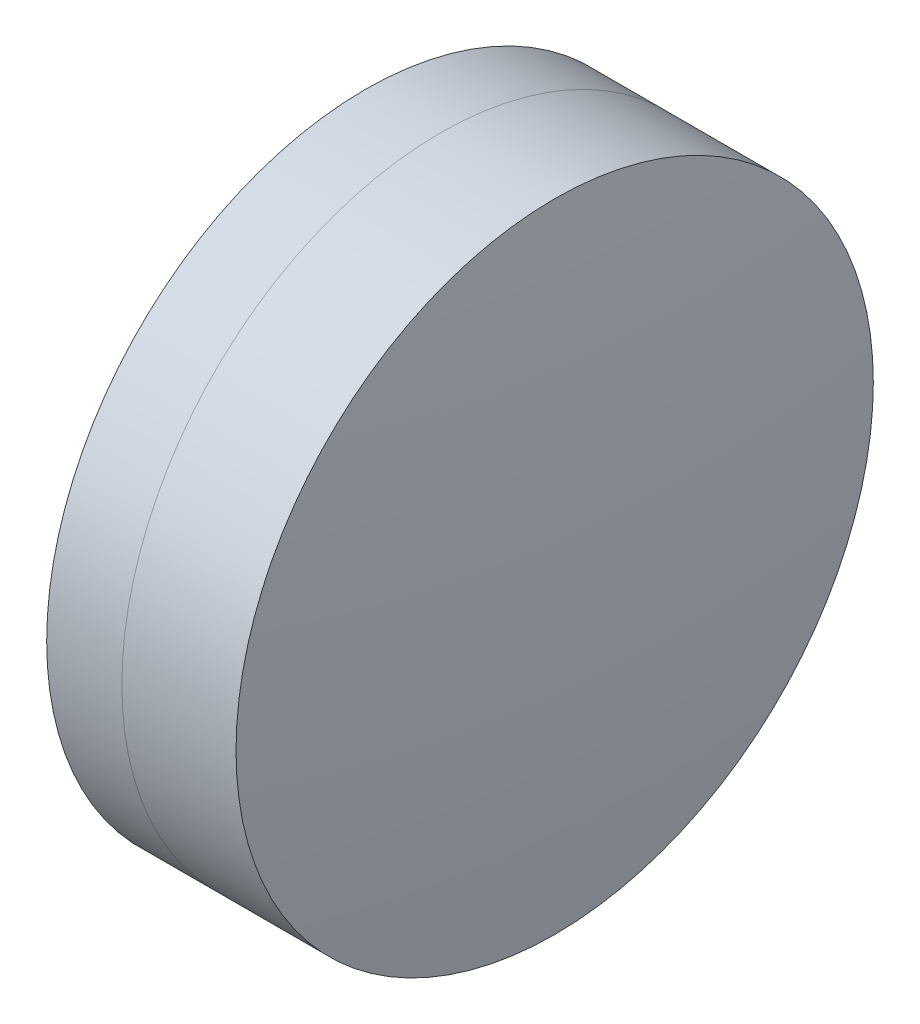
from build123d import *


with BuildPart() as part:
    # 草图1 one side → 旋转1 (revolve)
    with BuildSketch(Plane(origin=(0, 0, 0), x_dir=(1, 0, 0), z_dir=(0, 1, 0)), mode=Mode.PRIVATE) as revolve_1_sk:
        with BuildLine():
            ThreePointArc((241.249313087, 12.7), (240.010949636, 6.403591844), (239.595845808, 0))
            Line((239.595845808, 0), (246.595845808, 0))
            ThreePointArc((246.595845808, 0), (246.003546098, 6.457744226), (244.246411414, 12.7))
            Line((244.246411414, 12.7), (241.249313087, 12.7))
        make_face()
    revolve(revolve_1_sk.sketch.rotate(Axis((161.833171693, 0, 0), (1, 0, 0)), 180), axis=Axis((161.833171693, 0, 0), (1, 0, 0)))  # turned: the seam where the file's is


with BuildPart() as body_2:
    # 草图2 one side → 旋转3 (revolve)
    with BuildSketch(Plane(origin=(0, 0, 0), x_dir=(1, 0, 0), z_dir=(0, 1, 0)), mode=Mode.PRIVATE) as revolve_3_sk:
        with BuildLine():
            Line((248.795796008, 12.7), (244.246411414, 12.7))
            ThreePointArc((244.246411414, 12.7), (246.003546098, 6.457744226), (246.595845808, 0))
            Line((246.595845808, 0), (249.595845808, 0))
            ThreePointArc((249.595845808, 0), (249.395635314, 6.362587518), (248.795796008, 12.7))
        make_face()
    revolve(revolve_3_sk.sketch.rotate(Axis((-0.551919993, 0, 0), (1, 0, 0)), 180), axis=Axis((-0.551919993, 0, 0), (1, 0, 0)))  # turned: the seam where the file's is


solid = Compound([part.part, body_2.part])
